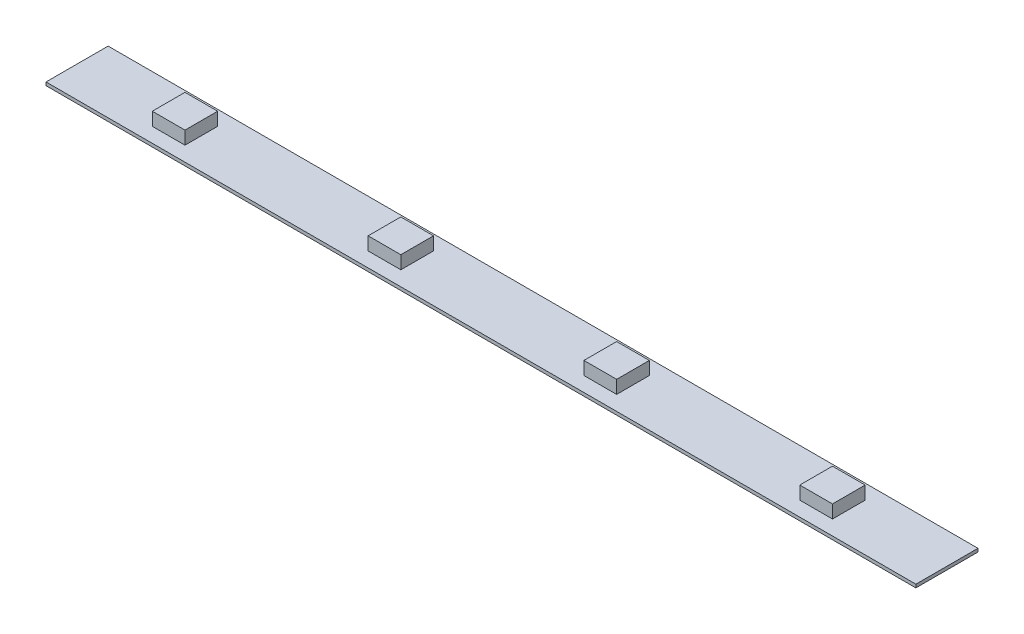
from build123d import *

# Parameters (mm, degrees)
ESQUISSE1_W        = 133
ESQUISSE1_H        = 9.5
BOSS_EXTRU_1_DEPTH = 0.5
ESQUISSE2_W        = 5
ESQUISSE2_H        = 5
BOSS_EXTRU_2_DEPTH = 2


with BuildPart() as part:
    # Esquisse1 → Boss.-Extru.1 (new body)
    with BuildSketch(Plane(origin=(0, 0, 0), x_dir=(1, 0, 0), z_dir=(0, 1, 0))):
        with Locations((66.5, 4.75)):
            Rectangle(ESQUISSE1_W, ESQUISSE1_H)
    extrude(amount=BOSS_EXTRU_1_DEPTH)

    # Esquisse2 → Boss.-Extru.2 (add)
    with BuildSketch(Plane(origin=(0, 0.5, 0), x_dir=(1, 0, 0), z_dir=(0, 1, 0))):
        with Locations((16.5, 4.75)):
            Rectangle(ESQUISSE2_W, ESQUISSE2_H)
        with Locations((49.5, 4.75)):
            Rectangle(ESQUISSE2_W, ESQUISSE2_H)
        with Locations((82.5, 4.75)):
            Rectangle(ESQUISSE2_W, ESQUISSE2_H)
        with Locations((115.5, 4.75)):
            Rectangle(ESQUISSE2_W, ESQUISSE2_H)
    extrude(amount=BOSS_EXTRU_2_DEPTH)


solid = part.part
